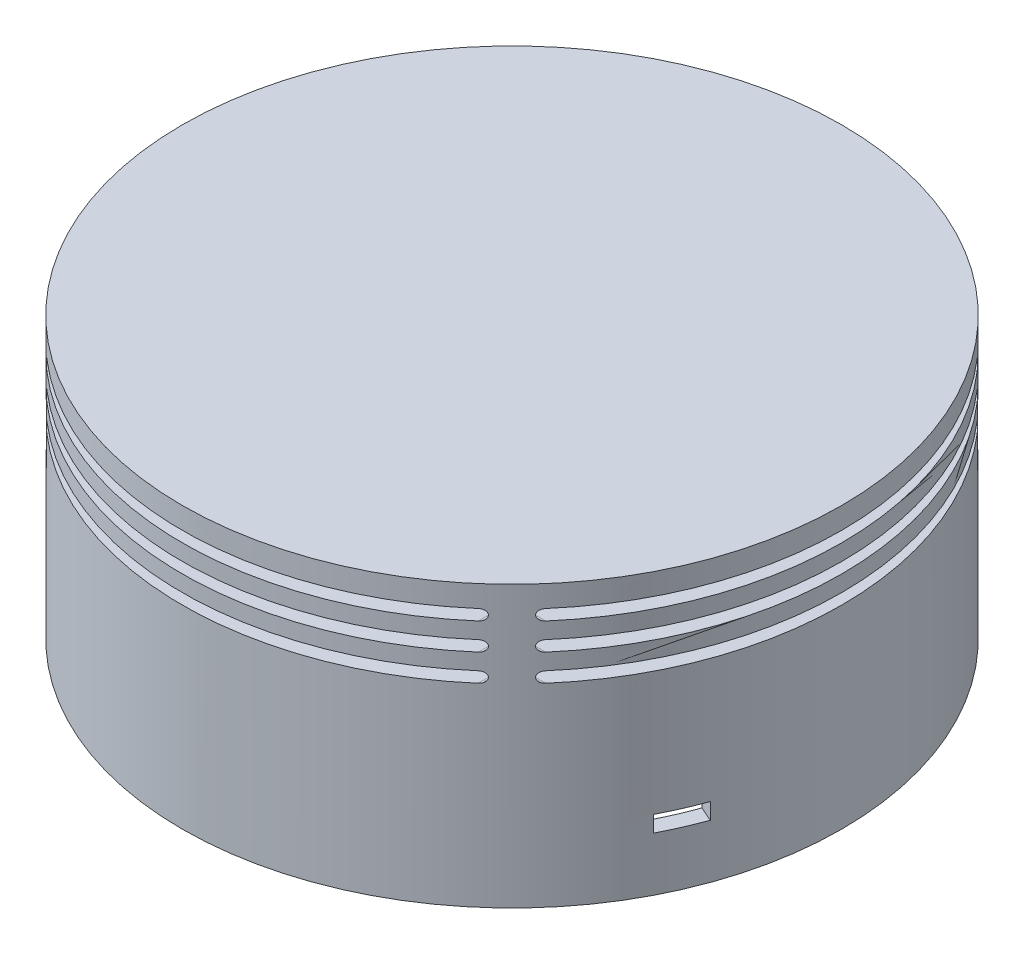
from build123d import *

# Parameters (mm, degrees)
SKIZZE1_R                                   = 61.154328933
SKIZZE1_R_2                                 = 58.154328933
LINEAR_AUSTRAGEN_D_NN1_DEPTH                = 50
SKIZZE2_R                                   = 61.154328933
AUFSATZ_LINEAR_AUSTRAGEN1_DEPTH             = 2
AUFSATZ_LINEAR_AUSTRAGEN2_REACH             = 102.914
SKIZZE3_W                                   = 9.9
SKIZZE3_H                                   = 4.9
AUFSATZ_LINEAR_AUSTRAGEN2_DIRECTION_2_REACH = 102.914
SCHNITT_LINEAR_AUSTRAGEN1_REACH             = 99.646
SKIZZE4_R                                   = 55.154328933
KREISMUSTER2_COUNT                          = 2
KREISMUSTER2_ANGLE                          = 90
SCHNITT_LINEAR_AUSTRAGEN2_REACH             = 99.646
SKIZZE5_R                                   = 55.154328933
SKIZZE6_R                                   = 3.5
SKIZZE6_R_2                                 = 1.5
LINEAR_AUSTRAGEN_D_NN2_DEPTH                = 21
LINEAR_AUSTRAGEN_D_NN3_REACH                = 144.501
SKIZZE8_R                                   = 2.5
SKIZZE8_R_2                                 = 1.5
SCHNITT_LINEAR_AUSTRAGEN3_REACH             = 144.501
SKIZZE9_R                                   = 1.5
SCHNITT_LINEAR_START                        = -11
SCHNITT_LINEAR_AUSTRAGEN4_DEPTH             = 11
SCHNITT_LINEAR_AUSTRAGEN5_REACH             = 148.299
KREISMUSTER5_COUNT                          = 4
SCHNITT_LINEAR_AUSTRAGEN6_REACH             = 156.179
SKIZZE13_W                                  = 8
SKIZZE13_H                                  = 3


with BuildPart() as part:
    # Skizze1 → Linear-Austragen-Dünn1 (new body)
    with BuildSketch(Plane(origin=(0, 0, 0), x_dir=(1, 0, 0), z_dir=(0, 1, 0))):
        Circle(SKIZZE1_R)
        Circle(SKIZZE1_R_2, mode=Mode.SUBTRACT)
    extrude(amount=LINEAR_AUSTRAGEN_D_NN1_DEPTH)

    # Skizze2 → Aufsatz-Linear austragen1 (add)
    with BuildSketch(Plane(origin=(0, 50, 0), x_dir=(1, 0, 0), z_dir=(0, 1, 0))):
        Circle(SKIZZE2_R)
    extrude(amount=AUFSATZ_LINEAR_AUSTRAGEN1_DEPTH)

    # Skizze3 → Aufsatz-Linear austragen2 (add, up to next)
    with BuildSketch(Plane.XY, mode=Mode.PRIVATE) as aufsatz_linear_austragen2_sk1:
        with Locations((0, 9.116666667)):
            Rectangle(SKIZZE3_W, SKIZZE3_H)
    aufsatz_linear_austragen2_tool1 = extrude(aufsatz_linear_austragen2_sk1.sketch, amount=AUFSATZ_LINEAR_AUSTRAGEN2_REACH, mode=Mode.PRIVATE) - part.part
    aufsatz_linear_austragen2 = aufsatz_linear_austragen2_tool1.solids().sort_by_distance((0, 9.116667, 0))[0]
    add(aufsatz_linear_austragen2)

    # Skizze3 → Aufsatz-Linear austragen2 direction 2 (add, up to next)
    with BuildSketch(Plane.XY, mode=Mode.PRIVATE) as aufsatz_linear_austragen2_direction_2_sk1:
        with Locations((0, 9.116666667)):
            Rectangle(SKIZZE3_W, SKIZZE3_H)
    aufsatz_linear_austragen2_direction_2_tool1 = extrude(aufsatz_linear_austragen2_direction_2_sk1.sketch, amount=-AUFSATZ_LINEAR_AUSTRAGEN2_DIRECTION_2_REACH, mode=Mode.PRIVATE) - part.part
    aufsatz_linear_austragen2_direction_2 = aufsatz_linear_austragen2_direction_2_tool1.solids().sort_by_distance((0, 9.116667, 0))[0]
    add(aufsatz_linear_austragen2_direction_2)

    # Skizze4 → Schnitt-Linear austragen1 (cut, up to next)
    with BuildSketch(Plane.XZ.offset(-6.666666667), mode=Mode.PRIVATE) as schnitt_linear_austragen1_sk1:
        Circle(SKIZZE4_R)
    schnitt_linear_austragen1_tool1 = extrude(schnitt_linear_austragen1_sk1.sketch, amount=-SCHNITT_LINEAR_AUSTRAGEN1_REACH, mode=Mode.PRIVATE) & part.part
    add(schnitt_linear_austragen1_tool1.solids().sort_by_distance((0, 6.666667, 0))[0], mode=Mode.SUBTRACT)

    # Kreismuster2: Aufsatz-Linear austragen2, Aufsatz-Linear austragen2 direction 2 ×2 about axis
    kreismuster2_axis = Axis((0, 50, 0), (0, 1, 0))
    add([aufsatz_linear_austragen2.rotate(kreismuster2_axis, i * KREISMUSTER2_ANGLE / (KREISMUSTER2_COUNT - 1)) for i in range(1, KREISMUSTER2_COUNT)])
    add([aufsatz_linear_austragen2_direction_2.rotate(kreismuster2_axis, i * KREISMUSTER2_ANGLE / (KREISMUSTER2_COUNT - 1)) for i in range(1, KREISMUSTER2_COUNT)])

    # Skizze5 → Schnitt-Linear austragen2 (cut, up to next)
    with BuildSketch(Plane(origin=(0, 6.666666667, 0), x_dir=(-1, 0, 0), z_dir=(0, -1, 0)), mode=Mode.PRIVATE) as schnitt_linear_austragen2_sk1:
        Circle(SKIZZE5_R)
    schnitt_linear_austragen2_tool1 = extrude(schnitt_linear_austragen2_sk1.sketch, amount=-SCHNITT_LINEAR_AUSTRAGEN2_REACH, mode=Mode.PRIVATE) & part.part
    add(schnitt_linear_austragen2_tool1.solids().sort_by_distance((0, 6.666667, 0))[0], mode=Mode.SUBTRACT)

    # Skizze6 → Linear-Austragen-Dünn2 (add)
    # profile 1 of 3: a face of its own
    with BuildSketch(Plane.XZ.offset(-50)):
        with Locations((25, 15)):
            Circle(SKIZZE6_R)
        with Locations((25, 15)):
            Circle(SKIZZE6_R_2, mode=Mode.SUBTRACT)
    # profile 2 of 3: a face of its own
    with BuildSketch(Plane.XZ.offset(-50)):
        with Locations((-11, -40)):
            Circle(SKIZZE6_R)
        with Locations((-11, -40)):
            Circle(SKIZZE6_R_2, mode=Mode.SUBTRACT)
    # profile 3 of 3: a face of its own
    with BuildSketch(Plane.XZ.offset(-50)):
        with Locations((-35, 15)):
            Circle(SKIZZE6_R)
        with Locations((-35, 15)):
            Circle(SKIZZE6_R_2, mode=Mode.SUBTRACT)
    extrude(amount=LINEAR_AUSTRAGEN_D_NN2_DEPTH)

    # Skizze8 → Linear-Austragen-Dünn3 (add, up to next)
    with BuildSketch(Plane(origin=(-44.308028502, 0, -19.345601333), x_dir=(-0.40013885674612404, 0, 0.9164545244156443), z_dir=(-0.9164545244156443, 0, -0.40013885674612404)), mode=Mode.PRIVATE) as linear_austragen_d_nn3_sk1:
        with Locations((10.743346448, 32.5)):
            Circle(SKIZZE8_R)
        with Locations((10.743346448, 32.5)):
            Circle(SKIZZE8_R_2, mode=Mode.SUBTRACT)
    linear_austragen_d_nn3_tool1 = extrude(linear_austragen_d_nn3_sk1.sketch, amount=LINEAR_AUSTRAGEN_D_NN3_REACH, mode=Mode.PRIVATE) - part.part
    add(linear_austragen_d_nn3_tool1.solids().sort_by_distance((-47.634806, 32.5, -11.726146))[0])

    # Skizze9 → Schnitt-Linear austragen3 (cut, up to next)
    with BuildSketch(Plane(origin=(-44.308028502, 0, -19.345601333), x_dir=(0.40013885674612404, 0, -0.9164545244156443), z_dir=(0.9164545244156443, 0, 0.40013885674612404)), mode=Mode.PRIVATE) as schnitt_linear_austragen3_sk1:
        with Locations((-10.743346448, 32.5)):
            Circle(SKIZZE9_R)
    schnitt_linear_austragen3_tool1 = extrude(schnitt_linear_austragen3_sk1.sketch, amount=-SCHNITT_LINEAR_AUSTRAGEN3_REACH, mode=Mode.PRIVATE) & part.part
    add(schnitt_linear_austragen3_tool1.solids().sort_by_distance((-48.606859, 32.5, -9.499813))[0], mode=Mode.SUBTRACT)

    # Skizze10 → Schnitt-Linear austragen4 (cut)
    with BuildSketch(Plane.XZ.offset(-29).offset(SCHNITT_LINEAR_START)):
        with BuildLine():
            Line((21.818402938, 13.541425306), (26.882869219, 12.049609601))
            ThreePointArc((26.882869219, 12.049609601), (24.011034871, 11.642627817), (21.818402938, 13.541425306))
        make_face()
        with BuildLine():
            Line((-7.61780527, -40.90042146), (-9.28980263, -37.070976956))
            Line((-9.28980263, -37.070976956), (-13.872075252, -39.07167124))
            Line((-13.872075252, -39.07167124), (-14.432592928, -39.316402316))
            ThreePointArc((-14.432592928, -39.316402316), (-10.207589654, -36.590881955), (-7.61780527, -40.90042146))
        make_face()
    extrude(amount=SCHNITT_LINEAR_AUSTRAGEN4_DEPTH, mode=Mode.SUBTRACT)

    # Skizze12 → Schnitt-Linear austragen5 (cut, up to next)
    with BuildSketch(Plane(origin=(0, 0, -61.154328933), x_dir=(-1, 0, 0), z_dir=(0, 0, -1)), mode=Mode.PRIVATE) as schnitt_linear_austragen5_sk1:
        with BuildLine():
            Line((-40, 38), (40, 38))
            ThreePointArc((40, 38), (41, 37), (40, 36))
            Line((40, 36), (-40, 36))
            ThreePointArc((-40, 36), (-41, 37), (-40, 38))
        make_face()
    schnitt_linear_austragen5_tool1 = extrude(schnitt_linear_austragen5_sk1.sketch, amount=-SCHNITT_LINEAR_AUSTRAGEN5_REACH, mode=Mode.PRIVATE) & part.part
    # Skizze12 → Schnitt-Linear austragen5 (cut, up to next)
    with BuildSketch(Plane(origin=(0, 0, -61.154328933), x_dir=(-1, 0, 0), z_dir=(0, 0, -1)), mode=Mode.PRIVATE) as schnitt_linear_austragen5_sk2:
        with BuildLine():
            Line((-40, 43), (40, 43))
            ThreePointArc((40, 43), (41, 42), (40, 41))
            Line((40, 41), (-40, 41))
            ThreePointArc((-40, 41), (-41, 42), (-40, 43))
        make_face()
    schnitt_linear_austragen5_tool2 = extrude(schnitt_linear_austragen5_sk2.sketch, amount=-SCHNITT_LINEAR_AUSTRAGEN5_REACH, mode=Mode.PRIVATE) & part.part
    # Skizze12 → Schnitt-Linear austragen5 (cut, up to next)
    with BuildSketch(Plane(origin=(0, 0, -61.154328933), x_dir=(-1, 0, 0), z_dir=(0, 0, -1)), mode=Mode.PRIVATE) as schnitt_linear_austragen5_sk3:
        with BuildLine():
            Line((-40, 48), (40, 48))
            ThreePointArc((40, 48), (41, 47), (40, 46))
            Line((40, 46), (-40, 46))
            ThreePointArc((-40, 46), (-41, 47), (-40, 48))
        make_face()
    schnitt_linear_austragen5_tool3 = extrude(schnitt_linear_austragen5_sk3.sketch, amount=-SCHNITT_LINEAR_AUSTRAGEN5_REACH, mode=Mode.PRIVATE) & part.part
    schnitt_linear_austragen5_1 = schnitt_linear_austragen5_tool1.solids().sort_by_distance((0, 37, -61.154329))[0]
    add(schnitt_linear_austragen5_1, mode=Mode.SUBTRACT)
    schnitt_linear_austragen5_2 = schnitt_linear_austragen5_tool2.solids().sort_by_distance((0, 42, -61.154329))[0]
    add(schnitt_linear_austragen5_2, mode=Mode.SUBTRACT)
    schnitt_linear_austragen5_3 = schnitt_linear_austragen5_tool3.solids().sort_by_distance((0, 47, -61.154329))[0]
    add(schnitt_linear_austragen5_3, mode=Mode.SUBTRACT)
    schnitt_linear_austragen5 = schnitt_linear_austragen5_1 + schnitt_linear_austragen5_2 + schnitt_linear_austragen5_3  # Schnitt-Linear austragen5 as one shape, for the pattern or mirror that repeats it

    # Kreismuster5: Schnitt-Linear austragen5 ×4 about axis
    kreismuster5_axis = Axis((0, 50, 0), (0, -1, 0))
    for i in range(1, KREISMUSTER5_COUNT):
        add(schnitt_linear_austragen5.rotate(kreismuster5_axis, i * 360 / KREISMUSTER5_COUNT), mode=Mode.SUBTRACT)

    # Skizze13 → Schnitt-Linear austragen6 (cut, up to next)
    with BuildSketch(Plane(origin=(56.045161438, 0, 24.470223264), x_dir=(0.40013885674612404, 0, -0.9164545244156443), z_dir=(0.9164545244156443, 0, 0.40013885674612404)), mode=Mode.PRIVATE) as schnitt_linear_austragen6_sk1:
        with Locations((0, 11.5)):
            Rectangle(SKIZZE13_W, SKIZZE13_H)
    schnitt_linear_austragen6_tool1 = extrude(schnitt_linear_austragen6_sk1.sketch, amount=-SCHNITT_LINEAR_AUSTRAGEN6_REACH, mode=Mode.PRIVATE) & part.part
    add(schnitt_linear_austragen6_tool1.solids().sort_by_distance((56.045161, 11.5, 24.470223))[0], mode=Mode.SUBTRACT)


solid = part.part
